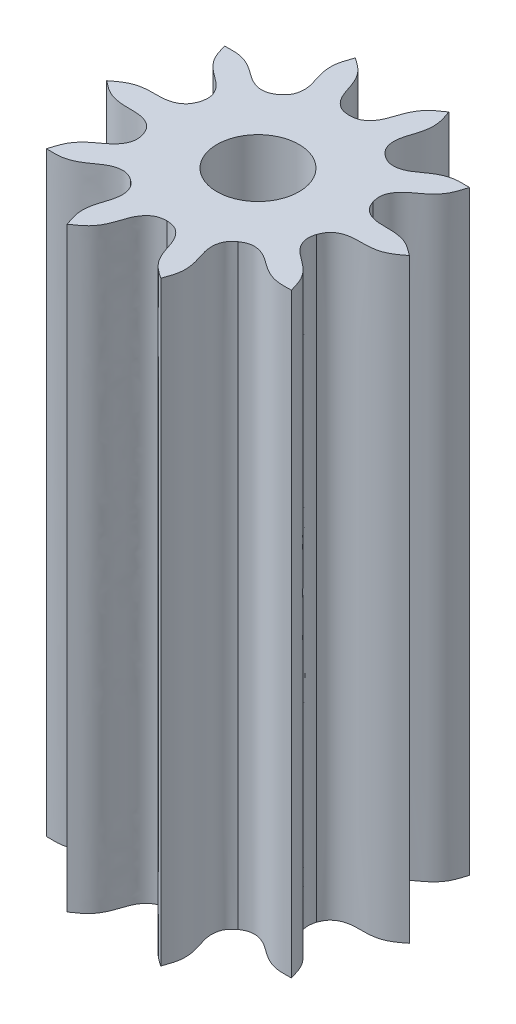
from build123d import *

# Parameters (mm, degrees)
SKETCH1_R           = 0.135
BOSS_EXTRUDE1_DEPTH = 1.96


with BuildPart() as part:
    # Sketch1 → Boss-Extrude1 (new body)
    with BuildSketch(Plane(origin=(0, 0, 0), x_dir=(1, 0, 0), z_dir=(0, 1, 0))):
        with BuildLine():
            add(Edge.make_bspline(
                [(0, 0.3), (-0.008002457, 0.300602495), (-0.023736253, 0.301787073), (-0.045361581, 0.314161102), (-0.062540556, 0.334948279), (-0.075080185, 0.364286352), (-0.085352075, 0.400976515), (-0.108864183, 0.443326409), (-0.137745473, 0.462827005), (-0.153932889, 0.473756719)],
                knots=[0, 0, 0, 0, 0.097339296, 0.191380791, 0.295712293, 0.422744131, 0.578988083, 0.76403079, 1, 1, 1, 1], degree=3))
            add(Edge.make_bspline(
                [(-0.176335576, 0.242705098), (-0.170215589, 0.247896254), (-0.158182958, 0.258102691), (-0.147960973, 0.280824539), (-0.146281286, 0.307739267), (-0.153381, 0.338844875), (-0.166636802, 0.374565506), (-0.172507751, 0.422647361), (-0.160604459, 0.45539967), (-0.153932889, 0.473756719)],
                knots=[0, 0, 0, 0, 0.097339296, 0.191380791, 0.295712293, 0.422744131, 0.578988083, 0.76403079, 1, 1, 1, 1], degree=3))
            add(Edge.make_bspline(
                [(-0.176335576, 0.242705098), (-0.183163837, 0.238488801), (-0.196589023, 0.230199051), (-0.221357552, 0.227498802), (-0.247474031, 0.234218434), (-0.274863291, 0.250582824), (-0.304739361, 0.274228124), (-0.3486537, 0.294669838), (-0.383481316, 0.293470155), (-0.403001536, 0.292797755)],
                knots=[0, 0, 0, 0, 0.097339296, 0.191380791, 0.295712293, 0.422744131, 0.578988083, 0.76403079, 1, 1, 1, 1], degree=3))
            add(Edge.make_bspline(
                [(-0.285316955, 0.092705098), (-0.283417066, 0.100502069), (-0.279681657, 0.115831853), (-0.284767464, 0.140222546), (-0.299228649, 0.162984314), (-0.323255856, 0.183976173), (-0.354976085, 0.205083205), (-0.387987588, 0.240531385), (-0.397608947, 0.27402514), (-0.403001536, 0.292797755)],
                knots=[0, 0, 0, 0, 0.097339296, 0.191380791, 0.295712293, 0.422744131, 0.578988083, 0.76403079, 1, 1, 1, 1], degree=3))
            add(Edge.make_bspline(
                [(-0.285316955, 0.092705098), (-0.288362857, 0.08528049), (-0.294351468, 0.070682816), (-0.312802462, 0.053939692), (-0.337880838, 0.044025107), (-0.369657962, 0.041165175), (-0.407726569, 0.04273391), (-0.455269353, 0.033459404), (-0.482740331, 0.01201768), (-0.498137294, 0)],
                knots=[0, 0, 0, 0, 0.097339296, 0.191380791, 0.295712293, 0.422744131, 0.578988083, 0.76403079, 1, 1, 1, 1], degree=3))
            add(Edge.make_bspline(
                [(-0.285316955, -0.092705098), (-0.288362857, -0.08528049), (-0.294351468, -0.070682816), (-0.312802462, -0.053939692), (-0.337880838, -0.044025107), (-0.369657962, -0.041165175), (-0.407726569, -0.04273391), (-0.455269353, -0.033459404), (-0.482740331, -0.01201768), (-0.498137294, 0)],
                knots=[0, 0, 0, 0, 0.097339296, 0.191380791, 0.295712293, 0.422744131, 0.578988083, 0.76403079, 1, 1, 1, 1], degree=3))
            add(Edge.make_bspline(
                [(-0.285316955, -0.092705098), (-0.283417066, -0.100502069), (-0.279681657, -0.115831853), (-0.284767464, -0.140222546), (-0.299228649, -0.162984314), (-0.323255856, -0.183976173), (-0.354976085, -0.205083205), (-0.387987588, -0.240531385), (-0.397608947, -0.27402514), (-0.403001536, -0.292797755)],
                knots=[0, 0, 0, 0, 0.097339296, 0.191380791, 0.295712293, 0.422744131, 0.578988083, 0.76403079, 1, 1, 1, 1], degree=3))
            add(Edge.make_bspline(
                [(-0.176335576, -0.242705098), (-0.183163837, -0.238488801), (-0.196589023, -0.230199051), (-0.221357552, -0.227498802), (-0.247474031, -0.234218434), (-0.274863291, -0.250582824), (-0.304739361, -0.274228124), (-0.3486537, -0.294669838), (-0.383481316, -0.293470155), (-0.403001536, -0.292797755)],
                knots=[0, 0, 0, 0, 0.097339296, 0.191380791, 0.295712293, 0.422744131, 0.578988083, 0.76403079, 1, 1, 1, 1], degree=3))
            add(Edge.make_bspline(
                [(-0.176335576, -0.242705098), (-0.170215589, -0.247896254), (-0.158182958, -0.258102691), (-0.147960973, -0.280824539), (-0.146281286, -0.307739267), (-0.153381, -0.338844875), (-0.166636802, -0.374565506), (-0.172507751, -0.422647361), (-0.160604459, -0.45539967), (-0.153932889, -0.473756719)],
                knots=[0, 0, 0, 0, 0.097339296, 0.191380791, 0.295712293, 0.422744131, 0.578988083, 0.76403079, 1, 1, 1, 1], degree=3))
            add(Edge.make_bspline(
                [(0, -0.3), (-0.008002457, -0.300602495), (-0.023736253, -0.301787073), (-0.045361581, -0.314161102), (-0.062540556, -0.334948279), (-0.075080185, -0.364286352), (-0.085352075, -0.400976515), (-0.108864183, -0.443326409), (-0.137745473, -0.462827005), (-0.153932889, -0.473756719)],
                knots=[0, 0, 0, 0, 0.097339296, 0.191380791, 0.295712293, 0.422744131, 0.578988083, 0.76403079, 1, 1, 1, 1], degree=3))
            add(Edge.make_bspline(
                [(0, -0.3), (0.008002457, -0.300602495), (0.023736253, -0.301787073), (0.045361581, -0.314161102), (0.062540556, -0.334948279), (0.075080185, -0.364286352), (0.085352075, -0.400976515), (0.108864183, -0.443326409), (0.137745473, -0.462827005), (0.153932889, -0.473756719)],
                knots=[0, 0, 0, 0, 0.097339296, 0.191380791, 0.295712293, 0.422744131, 0.578988083, 0.76403079, 1, 1, 1, 1], degree=3))
            add(Edge.make_bspline(
                [(0.176335576, -0.242705098), (0.170215589, -0.247896254), (0.158182958, -0.258102691), (0.147960973, -0.280824539), (0.146281286, -0.307739267), (0.153381, -0.338844875), (0.166636802, -0.374565506), (0.172507751, -0.422647361), (0.160604459, -0.45539967), (0.153932889, -0.473756719)],
                knots=[0, 0, 0, 0, 0.097339296, 0.191380791, 0.295712293, 0.422744131, 0.578988083, 0.76403079, 1, 1, 1, 1], degree=3))
            add(Edge.make_bspline(
                [(0.176335576, -0.242705098), (0.183163837, -0.238488801), (0.196589023, -0.230199051), (0.221357552, -0.227498802), (0.247474031, -0.234218434), (0.274863291, -0.250582824), (0.304739361, -0.274228124), (0.3486537, -0.294669838), (0.383481316, -0.293470155), (0.403001536, -0.292797755)],
                knots=[0, 0, 0, 0, 0.097339296, 0.191380791, 0.295712293, 0.422744131, 0.578988083, 0.76403079, 1, 1, 1, 1], degree=3))
            add(Edge.make_bspline(
                [(0.285316955, -0.092705098), (0.283417066, -0.100502069), (0.279681657, -0.115831853), (0.284767464, -0.140222546), (0.299228649, -0.162984314), (0.323255856, -0.183976173), (0.354976085, -0.205083205), (0.387987588, -0.240531385), (0.397608947, -0.27402514), (0.403001536, -0.292797755)],
                knots=[0, 0, 0, 0, 0.097339296, 0.191380791, 0.295712293, 0.422744131, 0.578988083, 0.76403079, 1, 1, 1, 1], degree=3))
            add(Edge.make_bspline(
                [(0.285316955, -0.092705098), (0.288362857, -0.08528049), (0.294351468, -0.070682816), (0.312802462, -0.053939692), (0.337880838, -0.044025107), (0.369657962, -0.041165175), (0.407726569, -0.04273391), (0.455269353, -0.033459404), (0.482740331, -0.01201768), (0.498137294, 0)],
                knots=[0, 0, 0, 0, 0.097339296, 0.191380791, 0.295712293, 0.422744131, 0.578988083, 0.76403079, 1, 1, 1, 1], degree=3))
            add(Edge.make_bspline(
                [(0.285316955, 0.092705098), (0.288362857, 0.08528049), (0.294351468, 0.070682816), (0.312802462, 0.053939692), (0.337880838, 0.044025107), (0.369657962, 0.041165175), (0.407726569, 0.04273391), (0.455269353, 0.033459404), (0.482740331, 0.01201768), (0.498137294, 0)],
                knots=[0, 0, 0, 0, 0.097339296, 0.191380791, 0.295712293, 0.422744131, 0.578988083, 0.76403079, 1, 1, 1, 1], degree=3))
            add(Edge.make_bspline(
                [(0.285316955, 0.092705098), (0.283417066, 0.100502069), (0.279681657, 0.115831853), (0.284767464, 0.140222546), (0.299228649, 0.162984314), (0.323255856, 0.183976173), (0.354976085, 0.205083205), (0.387987588, 0.240531385), (0.397608947, 0.27402514), (0.403001536, 0.292797755)],
                knots=[0, 0, 0, 0, 0.097339296, 0.191380791, 0.295712293, 0.422744131, 0.578988083, 0.76403079, 1, 1, 1, 1], degree=3))
            add(Edge.make_bspline(
                [(0.176335576, 0.242705098), (0.183163837, 0.238488801), (0.196589023, 0.230199051), (0.221357552, 0.227498802), (0.247474031, 0.234218434), (0.274863291, 0.250582824), (0.304739361, 0.274228124), (0.3486537, 0.294669838), (0.383481316, 0.293470155), (0.403001536, 0.292797755)],
                knots=[0, 0, 0, 0, 0.097339296, 0.191380791, 0.295712293, 0.422744131, 0.578988083, 0.76403079, 1, 1, 1, 1], degree=3))
            add(Edge.make_bspline(
                [(0.176335576, 0.242705098), (0.170215589, 0.247896254), (0.158182958, 0.258102691), (0.147960973, 0.280824539), (0.146281286, 0.307739267), (0.153381, 0.338844875), (0.166636802, 0.374565506), (0.172507751, 0.422647361), (0.160604459, 0.45539967), (0.153932889, 0.473756719)],
                knots=[0, 0, 0, 0, 0.097339296, 0.191380791, 0.295712293, 0.422744131, 0.578988083, 0.76403079, 1, 1, 1, 1], degree=3))
            add(Edge.make_bspline(
                [(0, 0.3), (0.008002457, 0.300602495), (0.023736253, 0.301787073), (0.045361581, 0.314161102), (0.062540556, 0.334948279), (0.075080185, 0.364286352), (0.085352075, 0.400976515), (0.108864183, 0.443326409), (0.137745473, 0.462827005), (0.153932889, 0.473756719)],
                knots=[0, 0, 0, 0, 0.097339296, 0.191380791, 0.295712293, 0.422744131, 0.578988083, 0.76403079, 1, 1, 1, 1], degree=3))
        make_face()
        Circle(SKETCH1_R, mode=Mode.SUBTRACT)
    extrude(amount=BOSS_EXTRUDE1_DEPTH)


solid = part.part
